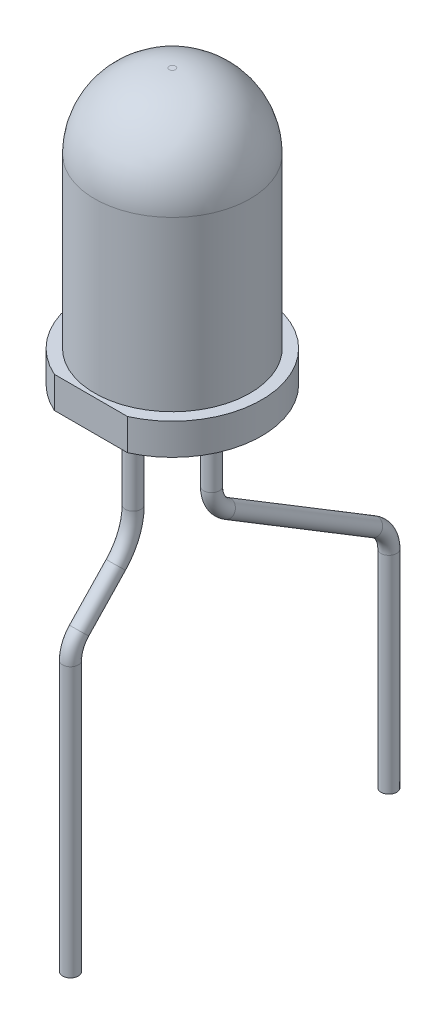
from build123d import *

# Parameters (mm, degrees)
CUT_EXTRUDE1_DEPTH    = 1
SKETCH3_R             = 0.25
BOSS_EXTRUDE1_DEPTH   = 2
SKETCH5_R             = 0.25
SKETCH7_R             = 0.25
SKETCH8_R             = 0.25
BOSS_EXTRUDE2_DEPTH   = 3
BOSS_EXTRUDE2_2_DEPTH = 3
SKETCH11_R            = 0.25
CUT_EXTRUDE2_DEPTH    = 1.5
SKETCH9_R             = 0.5
BOSS_EXTRUDE3_DEPTH   = 0.2
FILLET1_R             = 0.15
BOSS_EXTRUDE4_DEPTH   = 0.15
FILLET2_R             = 0.1
FILLET3_R             = 0.1


with BuildPart() as part:
    # Sketch1 → Revolve1 (revolve)
    with BuildSketch(Plane.XY, mode=Mode.PRIVATE) as revolve1_sk:
        with BuildLine():
            Line((0, 0), (0, 8.75))
            Line((0, 8.75), (0.1, 8.75))
            ThreePointArc((0.1, 8.75), (1.782914139, 8.052914139), (2.48, 6.37))
            Line((2.48, 6.37), (2.48, 1))
            Line((2.48, 1), (2.85, 1))
            Line((2.85, 1), (2.85, 0))
            Line((2.85, 0), (0, 0))
        make_face()
    revolve(revolve1_sk.sketch.rotate(Axis((0, 0, 0), (0, 1, 0)), 90), axis=Axis((0, 0, 0), (0, 1, 0)))

    # Sketch2 → Cut-Extrude1 (cut)
    with BuildSketch(Plane.XZ):
        with BuildLine():
            Line((-1.167261753, 2.6), (1.167261753, 2.6))
            ThreePointArc((1.167261753, 2.6), (0, 2.85), (-1.167261753, 2.6))
        make_face()
    extrude(amount=-CUT_EXTRUDE1_DEPTH, mode=Mode.SUBTRACT)

    # Sketch3 → Boss-Extrude1 (add)
    with BuildSketch(Plane.XZ):
        with Locations(Location((0, -1.25, 0), (0, 0, 270))):
            Circle(SKETCH3_R)
        with Locations(Location((0, 1.25, 0), (0, 0, 270))):
            Circle(SKETCH3_R)
    extrude(amount=BOSS_EXTRUDE1_DEPTH)

    # Sweep1: sweep along a path in Sketch4
    with BuildLine(Plane(origin=(0, 0, 0), x_dir=(0, 0, -1), z_dir=(1, 0, 0))) as sweep1_path:
        Line((-1.25, -2), (-1.25, -2.7))
        ThreePointArc((-1.25, -2.7), (-1.393046618, -3.442781353), (-1.801724138, -4.079310345))
        Line((-1.801724138, -4.079310345), (-2.974137931, -5.310344828))
        ThreePointArc((-2.974137931, -5.310344828), (-3.178476691, -5.628609324), (-3.25, -6))
        Line((-3.25, -6), (-3.25, -14.6))
    # Sketch5 → Sweep1 (sweep)
    with BuildSketch(Plane(origin=(0, -14.6, 3.25), x_dir=(-1, 0, 0), z_dir=(0, -1, 0))):
        Circle(SKETCH5_R)
    sweep(path=sweep1_path.line)

    # Sweep2: sweep along a path in Sketch6
    with BuildLine(Plane(origin=(0, 0, 0), x_dir=(0, 0, -1), z_dir=(1, 0, 0))) as sweep2_path:
        Line((6.91, -14.6), (6.91, -8))
        ThreePointArc((6.91, -8), (6.78151551, -7.50963206), (6.429078567, -7.14527347))
        Line((6.429078567, -7.14527347), (1.730921433, -4.292065356))
        ThreePointArc((1.730921433, -4.292065356), (1.37848449, -3.927706766), (1.25, -3.437338826))
        Line((1.25, -3.437338826), (1.25, -2))
    # Sketch7 → Sweep2 (sweep)
    with BuildSketch(Plane(origin=(0, -14.6, -6.91), x_dir=(-1, 0, 0), z_dir=(0, -1, 0))):
        Circle(SKETCH7_R)
    sweep(path=sweep2_path.line)


with BuildPart() as body_2:
    # Sketch8 → Boss-Extrude2 (new body)
    with BuildSketch(Plane.XZ):
        with Locations(Location((0, 1.25, 0), (0, 0, 270))):
            Circle(SKETCH8_R)
    extrude(amount=-BOSS_EXTRUDE2_DEPTH)

    # Sketch9 → Boss-Extrude3 (add)
    with BuildSketch(Plane(origin=(0, 3, 0), x_dir=(1, 0, 0), z_dir=(0, 1, 0))):
        with Locations(Location((0, -1.25, 0), (0, 0, 270))):
            Circle(SKETCH9_R)
    extrude(amount=BOSS_EXTRUDE3_DEPTH)

    # Fillet1
    fillet1_edges = [body_2.edges().sort_by_distance(p)[0] for p in [
        (0, 3.2, 0.75),
    ]]
    fillet(fillet1_edges, radius=FILLET1_R)

    # Sketch10 → Boss-Extrude4 (add, symmetric)
    with BuildSketch(Plane(origin=(0, 0, 0), x_dir=(0, 0, -1), z_dir=(1, 0, 0))):
        with BuildLine():
            Line((-1.25, 3), (-1.25, 1.4))
            Line((-1.25, 1.4), (-0.75, 1.4))
            ThreePointArc((-0.75, 1.4), (-0.148588401, 1.492566099), (0.397152873, 1.761695911))
            Line((0.397152873, 1.761695911), (1.407892729, 2.469423578))
            ThreePointArc((1.407892729, 2.469423578), (1.45, 2.561669844), (1.389833509, 2.643293303))
            Line((1.389833509, 2.643293303), (0.931687151, 2.839090416))
            ThreePointArc((0.931687151, 2.839090416), (0.546854046, 2.959359696), (0.145718678, 3))
            Line((0.145718678, 3), (-1.25, 3))
        make_face()
        with BuildLine():
            Line((1.5, 1.5), (1.5, 2.1))
            ThreePointArc((1.5, 2.1), (1.266795249, 1.799807126), (0.9, 1.7))
            Line((0.9, 1.7), (0.9, 1.1))
            Line((0.9, 1.1), (1.5, 1.1))
            Line((1.5, 1.1), (1.5, 1.5))
        make_face()
    extrude(amount=BOSS_EXTRUDE4_DEPTH, both=True)


with BuildPart() as body_3:
    # Sketch8 → Boss-Extrude2 2 (new body)
    with BuildSketch(Plane.XZ):
        with Locations(Location((0, -1.25, 0), (0, 0, 270))):
            Circle(SKETCH8_R)
    extrude(amount=-BOSS_EXTRUDE2_2_DEPTH)

    # Sketch11 → Cut-Extrude2 (cut)
    with BuildSketch(Plane(origin=(0, 3, 0), x_dir=(1, 0, 0), z_dir=(0, 1, 0))):
        with Locations(Location((0, 1.25, 0), (0, 0, 90))):
            Circle(SKETCH11_R)
    extrude(amount=-CUT_EXTRUDE2_DEPTH, mode=Mode.SUBTRACT)

    # Fillet3
    fillet3_edges = [body_3.edges().sort_by_distance(p)[0] for p in [
        (0, 1.5, -1),
    ]]
    fillet(fillet3_edges, radius=FILLET3_R)


with BuildPart() as boss_extrude4_piece_1:
    # of the separate pieces the step leaves, piece 1, a body of its own (boss_extrude4_pieces)
    add(body_2.part.solids().sort_by_distance((0, 3.05, 1.75))[0])


with BuildPart() as boss_extrude4_piece_2:
    # of the separate pieces the step leaves, piece 2, a body of its own (boss_extrude4_pieces)
    add(body_2.part.solids().sort_by_distance((-0.15, 2.1, -1.5))[0])

    # Fillet2
    fillet2_edges = [boss_extrude4_piece_2.edges().sort_by_distance(p)[0] for p in [
        (0, 1.1, -1.5),
        (0, 1.1, -0.9),
        (0, 1.7, -0.9),
        (0, 2.1, -1.5),
    ]]
    fillet(fillet2_edges, radius=FILLET2_R)


solid = Compound([part.part, body_3.part, boss_extrude4_piece_1.part, boss_extrude4_piece_2.part])
